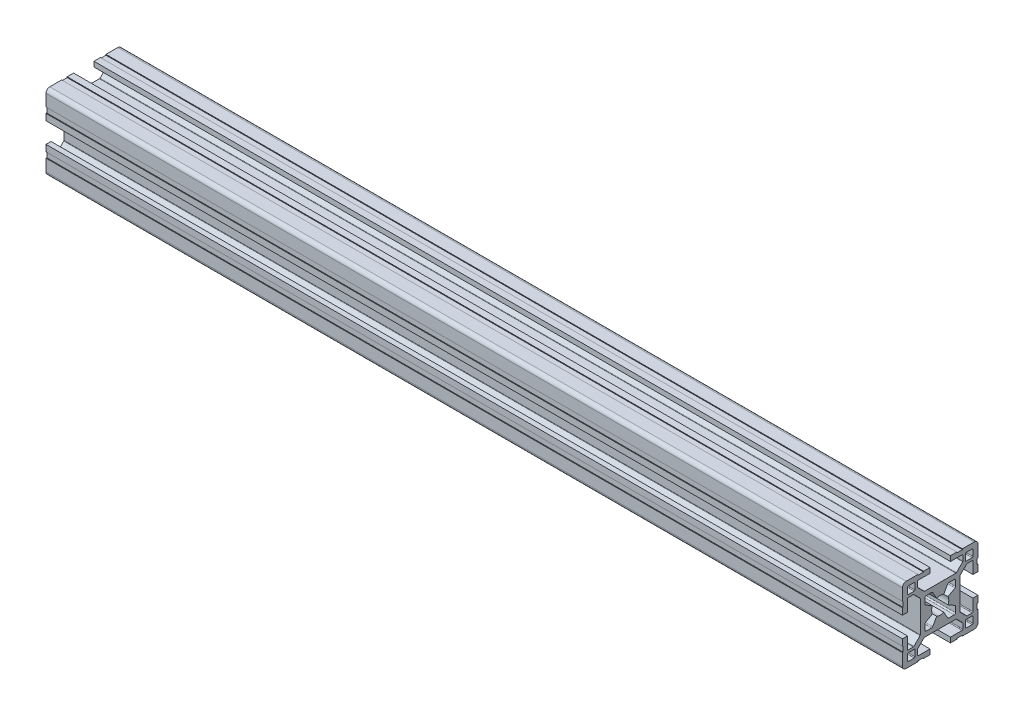
from build123d import *

# Parameters (mm, degrees)
QUADRADO_PF30_11_PERFIL_3030_CENTRO_M8_DEPTH = 340


with BuildPart() as part:
    # Sketch1 → Quadrado PF30-11 - PERFIL 3030 CENTRO M8(1) (new body)
    with BuildSketch(Plane.YZ):
        with BuildLine():
            Line((14.999995923, 6.599996803), (14.699995923, 6.599996803))
            Line((14.699995923, 6.599996803), (14.699995923, 8.799996803))
            Line((14.699995923, 8.799996803), (14.999995923, 8.799996803))
            Line((14.999995923, 8.799996803), (14.999995923, 13.499995825))
            ThreePointArc((14.999995923, 13.499995825), (14.560656066, 14.560656066), (13.499995825, 14.999995923))
            Line((13.499995825, 14.999995923), (8.799996818, 14.999995923))
            Line((8.799996818, 14.999995923), (8.799996818, 14.699995923))
            Line((8.799996818, 14.699995923), (6.599996818, 14.699995923))
            Line((6.599996818, 14.699995923), (6.599996818, 14.999995923))
            Line((6.599996818, 14.999995923), (4.0499987, 14.999995923))
            Line((4.0499987, 14.999995923), (4.0499987, 12.999995366))
            Line((4.0499987, 12.999995366), (8.699997649, 12.999995366))
            ThreePointArc((8.699997649, 12.999995366), (8.912129683, 12.9121274), (8.999997649, 12.699995366))
            Line((8.999997649, 12.699995366), (8.999997649, 10.679894006))
            ThreePointArc((8.999997649, 10.679894006), (8.977161511, 10.565088981), (8.912129691, 10.467761979))
            Line((8.912129691, 10.467761979), (6.432230191, 7.987862303))
            ThreePointArc((6.432230191, 7.987862303), (6.334903184, 7.922830472), (6.220098149, 7.89999433))
            Line((6.220098149, 7.89999433), (-6.220098149, 7.89999433))
            ThreePointArc((-6.220098149, 7.89999433), (-6.334903184, 7.922830472), (-6.432230191, 7.987862303))
            Line((-6.432230191, 7.987862303), (-8.912129691, 10.467761979))
            ThreePointArc((-8.912129691, 10.467761979), (-8.977161511, 10.565088981), (-8.999997649, 10.679894006))
            Line((-8.999997649, 10.679894006), (-8.999997649, 12.699995366))
            ThreePointArc((-8.999997649, 12.699995366), (-8.912129683, 12.9121274), (-8.699997649, 12.999995366))
            Line((-8.699997649, 12.999995366), (-4.0499987, 12.999995366))
            Line((-4.0499987, 12.999995366), (-4.0499987, 14.999995923))
            Line((-4.0499987, 14.999995923), (-6.599996818, 14.999995923))
            Line((-6.599996818, 14.999995923), (-6.599996818, 14.699995923))
            Line((-6.599996818, 14.699995923), (-8.799996818, 14.699995923))
            Line((-8.799996818, 14.699995923), (-8.799996818, 14.999995923))
            Line((-8.799996818, 14.999995923), (-13.499995825, 14.999995923))
            ThreePointArc((-13.499995825, 14.999995923), (-14.560656066, 14.560656066), (-14.999995923, 13.499995825))
            Line((-14.999995923, 13.499995825), (-14.999995923, 8.799996803))
            Line((-14.999995923, 8.799996803), (-14.699995923, 8.799996803))
            Line((-14.699995923, 8.799996803), (-14.699995923, 6.599996803))
            Line((-14.699995923, 6.599996803), (-14.999995923, 6.599996803))
            Line((-14.999995923, 6.599996803), (-14.999995923, 4.0499987))
            Line((-14.999995923, 4.0499987), (-12.999995366, 4.0499987))
            Line((-12.999995366, 4.0499987), (-12.999995366, 8.699997649))
            ThreePointArc((-12.999995366, 8.699997649), (-12.9121274, 8.912129683), (-12.699995366, 8.999997649))
            Line((-12.699995366, 8.999997649), (-10.679894006, 8.999997649))
            ThreePointArc((-10.679894006, 8.999997649), (-10.565088981, 8.977161511), (-10.467761979, 8.912129691))
            Line((-10.467761979, 8.912129691), (-7.987862303, 6.432230191))
            ThreePointArc((-7.987862303, 6.432230191), (-7.922830472, 6.334903184), (-7.89999433, 6.220098149))
            Line((-7.89999433, 6.220098149), (-7.89999433, -6.220098149))
            ThreePointArc((-7.89999433, -6.220098149), (-7.922830472, -6.334903184), (-7.987862303, -6.432230191))
            Line((-7.987862303, -6.432230191), (-10.467761979, -8.912129691))
            ThreePointArc((-10.467761979, -8.912129691), (-10.565088981, -8.977161511), (-10.679894006, -8.999997649))
            Line((-10.679894006, -8.999997649), (-12.699995366, -8.999997649))
            ThreePointArc((-12.699995366, -8.999997649), (-12.9121274, -8.912129683), (-12.999995366, -8.699997649))
            Line((-12.999995366, -8.699997649), (-12.999995366, -4.0499987))
            Line((-12.999995366, -4.0499987), (-14.999995923, -4.0499987))
            Line((-14.999995923, -4.0499987), (-14.999995923, -6.599996803))
            Line((-14.999995923, -6.599996803), (-14.699995923, -6.599996803))
            Line((-14.699995923, -6.599996803), (-14.699995923, -8.799996803))
            Line((-14.699995923, -8.799996803), (-14.999995923, -8.799996803))
            Line((-14.999995923, -8.799996803), (-14.999995923, -13.499995825))
            ThreePointArc((-14.999995923, -13.499995825), (-14.560656066, -14.560656066), (-13.499995825, -14.999995923))
            Line((-13.499995825, -14.999995923), (-8.799996818, -14.999995923))
            Line((-8.799996818, -14.999995923), (-8.799996818, -14.699995923))
            Line((-8.799996818, -14.699995923), (-6.599996818, -14.699995923))
            Line((-6.599996818, -14.699995923), (-6.599996818, -14.999995923))
            Line((-6.599996818, -14.999995923), (-4.0499987, -14.999995923))
            Line((-4.0499987, -14.999995923), (-4.0499987, -12.999995366))
            Line((-4.0499987, -12.999995366), (-8.699997649, -12.999995366))
            ThreePointArc((-8.699997649, -12.999995366), (-8.912129683, -12.9121274), (-8.999997649, -12.699995366))
            Line((-8.999997649, -12.699995366), (-8.999997649, -10.679894006))
            ThreePointArc((-8.999997649, -10.679894006), (-8.977161511, -10.565088981), (-8.912129691, -10.467761979))
            Line((-8.912129691, -10.467761979), (-6.432230191, -7.987862303))
            ThreePointArc((-6.432230191, -7.987862303), (-6.334903184, -7.922830472), (-6.220098149, -7.89999433))
            Line((-6.220098149, -7.89999433), (6.220098149, -7.89999433))
            ThreePointArc((6.220098149, -7.89999433), (6.334903184, -7.922830472), (6.432230191, -7.987862303))
            Line((6.432230191, -7.987862303), (8.912129691, -10.467761979))
            ThreePointArc((8.912129691, -10.467761979), (8.977161511, -10.565088981), (8.999997649, -10.679894006))
            Line((8.999997649, -10.679894006), (8.999997649, -12.699995366))
            ThreePointArc((8.999997649, -12.699995366), (8.912129683, -12.9121274), (8.699997649, -12.999995366))
            Line((8.699997649, -12.999995366), (4.0499987, -12.999995366))
            Line((4.0499987, -12.999995366), (4.0499987, -14.999995923))
            Line((4.0499987, -14.999995923), (6.599996818, -14.999995923))
            Line((6.599996818, -14.999995923), (6.599996818, -14.699995923))
            Line((6.599996818, -14.699995923), (8.799996818, -14.699995923))
            Line((8.799996818, -14.699995923), (8.799996818, -14.999995923))
            Line((8.799996818, -14.999995923), (13.499995825, -14.999995923))
            ThreePointArc((13.499995825, -14.999995923), (14.560656066, -14.560656066), (14.999995923, -13.499995825))
            Line((14.999995923, -13.499995825), (14.999995923, -8.799996803))
            Line((14.999995923, -8.799996803), (14.699995923, -8.799996803))
            Line((14.699995923, -8.799996803), (14.699995923, -6.599996803))
            Line((14.699995923, -6.599996803), (14.999995923, -6.599996803))
            Line((14.999995923, -6.599996803), (14.999995923, -4.0499987))
            Line((14.999995923, -4.0499987), (12.999995366, -4.0499987))
            Line((12.999995366, -4.0499987), (12.999995366, -8.699997649))
            ThreePointArc((12.999995366, -8.699997649), (12.9121274, -8.912129683), (12.699995366, -8.999997649))
            Line((12.699995366, -8.999997649), (10.679894006, -8.999997649))
            ThreePointArc((10.679894006, -8.999997649), (10.565088981, -8.977161511), (10.467761979, -8.912129691))
            Line((10.467761979, -8.912129691), (7.987862303, -6.432230191))
            ThreePointArc((7.987862303, -6.432230191), (7.922830472, -6.334903184), (7.89999433, -6.220098149))
            Line((7.89999433, -6.220098149), (7.89999433, 6.220098149))
            ThreePointArc((7.89999433, 6.220098149), (7.922830472, 6.334903184), (7.987862303, 6.432230191))
            Line((7.987862303, 6.432230191), (10.467761979, 8.912129691))
            ThreePointArc((10.467761979, 8.912129691), (10.565088981, 8.977161511), (10.679894006, 8.999997649))
            Line((10.679894006, 8.999997649), (12.699995366, 8.999997649))
            ThreePointArc((12.699995366, 8.999997649), (12.9121274, 8.912129683), (12.999995366, 8.699997649))
            Line((12.999995366, 8.699997649), (12.999995366, 4.0499987))
            Line((12.999995366, 4.0499987), (14.999995923, 4.0499987))
            Line((14.999995923, 4.0499987), (14.999995923, 6.599996803))
        make_face()
        with BuildLine():
            Line((-6.1, -3.425408784), (-6.1, -5.6))
            ThreePointArc((-6.1, -5.6), (-5.953553391, -5.953553391), (-5.6, -6.1))
            Line((-5.6, -6.1), (-3.425408784, -6.1))
            ThreePointArc((-3.425408784, -6.1), (-3.175408784, -6.033012702), (-2.992396082, -5.85))
            Line((-2.992396082, -5.85), (-1.402974441, -3.097040962))
            ThreePointArc((-1.402974441, -3.097040962), (0, -3.4), (1.402974441, -3.097040962))
            Line((1.402974441, -3.097040962), (2.992396082, -5.85))
            ThreePointArc((2.992396082, -5.85), (3.175408784, -6.033012702), (3.425408784, -6.1))
            Line((3.425408784, -6.1), (5.6, -6.1))
            ThreePointArc((5.6, -6.1), (5.953553391, -5.953553391), (6.1, -5.6))
            Line((6.1, -5.6), (6.1, -3.425408784))
            ThreePointArc((6.1, -3.425408784), (6.033012702, -3.175408784), (5.85, -2.992396082))
            Line((5.85, -2.992396082), (3.097040962, -1.402974441))
            ThreePointArc((3.097040962, -1.402974441), (3.4, 0), (3.097040962, 1.402974441))
            Line((3.097040962, 1.402974441), (5.85, 2.992396082))
            ThreePointArc((5.85, 2.992396082), (6.033012702, 3.175408784), (6.1, 3.425408784))
            Line((6.1, 3.425408784), (6.1, 5.6))
            ThreePointArc((6.1, 5.6), (5.953553391, 5.953553391), (5.6, 6.1))
            Line((5.6, 6.1), (3.425408784, 6.1))
            ThreePointArc((3.425408784, 6.1), (3.175408784, 6.033012702), (2.992396082, 5.85))
            Line((2.992396082, 5.85), (1.402974441, 3.097040962))
            ThreePointArc((1.402974441, 3.097040962), (0, 3.4), (-1.402974441, 3.097040962))
            Line((-1.402974441, 3.097040962), (-2.992396082, 5.85))
            ThreePointArc((-2.992396082, 5.85), (-3.175408784, 6.033012702), (-3.425408784, 6.1))
            Line((-3.425408784, 6.1), (-5.6, 6.1))
            ThreePointArc((-5.6, 6.1), (-5.953553391, 5.953553391), (-6.1, 5.6))
            Line((-6.1, 5.6), (-6.1, 3.425408784))
            ThreePointArc((-6.1, 3.425408784), (-6.033012702, 3.175408784), (-5.85, 2.992396082))
            Line((-5.85, 2.992396082), (-3.097040962, 1.402974441))
            ThreePointArc((-3.097040962, 1.402974441), (-3.4, 0), (-3.097040962, -1.402974441))
            Line((-3.097040962, -1.402974441), (-5.85, -2.992396082))
            ThreePointArc((-5.85, -2.992396082), (-6.033012702, -3.175408784), (-6.1, -3.425408784))
        make_face(mode=Mode.SUBTRACT)
        with BuildLine():
            Line((9.999995366, 12.699997649), (9.999995366, 10.299997649))
            ThreePointArc((9.999995366, 10.299997649), (10.087863331, 10.087865615), (10.299995366, 9.999997649))
            Line((10.299995366, 9.999997649), (12.699995366, 9.999997649))
            ThreePointArc((12.699995366, 9.999997649), (12.9121274, 10.087865615), (12.999995366, 10.299997649))
            Line((12.999995366, 10.299997649), (12.999995366, 12.699997649))
            ThreePointArc((12.999995366, 12.699997649), (12.9121274, 12.912129683), (12.699995366, 12.999997649))
            Line((12.699995366, 12.999997649), (10.299995366, 12.999997649))
            ThreePointArc((10.299995366, 12.999997649), (10.087863331, 12.912129683), (9.999995366, 12.699997649))
        make_face(mode=Mode.SUBTRACT)
        with BuildLine():
            Line((12.999995366, -12.699997649), (12.999995366, -10.299997649))
            ThreePointArc((12.999995366, -10.299997649), (12.9121274, -10.087865615), (12.699995366, -9.999997649))
            Line((12.699995366, -9.999997649), (10.299995366, -9.999997649))
            ThreePointArc((10.299995366, -9.999997649), (10.087863331, -10.087865615), (9.999995366, -10.299997649))
            Line((9.999995366, -10.299997649), (9.999995366, -12.699997649))
            ThreePointArc((9.999995366, -12.699997649), (10.087863331, -12.912129683), (10.299995366, -12.999997649))
            Line((10.299995366, -12.999997649), (12.699995366, -12.999997649))
            ThreePointArc((12.699995366, -12.999997649), (12.9121274, -12.912129683), (12.999995366, -12.699997649))
        make_face(mode=Mode.SUBTRACT)
        with BuildLine():
            Line((-10.299995366, -9.999997649), (-12.699995366, -9.999997649))
            ThreePointArc((-12.699995366, -9.999997649), (-12.9121274, -10.087865615), (-12.999995366, -10.299997649))
            Line((-12.999995366, -10.299997649), (-12.999995366, -12.699997649))
            ThreePointArc((-12.999995366, -12.699997649), (-12.9121274, -12.912129683), (-12.699995366, -12.999997649))
            Line((-12.699995366, -12.999997649), (-10.299995366, -12.999997649))
            ThreePointArc((-10.299995366, -12.999997649), (-10.087863331, -12.912129683), (-9.999995366, -12.699997649))
            Line((-9.999995366, -12.699997649), (-9.999995366, -10.299997649))
            ThreePointArc((-9.999995366, -10.299997649), (-10.087863331, -10.087865615), (-10.299995366, -9.999997649))
        make_face(mode=Mode.SUBTRACT)
        with BuildLine():
            Line((-12.999995366, 12.699997649), (-12.999995366, 10.299997649))
            ThreePointArc((-12.999995366, 10.299997649), (-12.9121274, 10.087865615), (-12.699995366, 9.999997649))
            Line((-12.699995366, 9.999997649), (-10.299995366, 9.999997649))
            ThreePointArc((-10.299995366, 9.999997649), (-10.087863331, 10.087865615), (-9.999995366, 10.299997649))
            Line((-9.999995366, 10.299997649), (-9.999995366, 12.699997649))
            ThreePointArc((-9.999995366, 12.699997649), (-10.087863331, 12.912129683), (-10.299995366, 12.999997649))
            Line((-10.299995366, 12.999997649), (-12.699995366, 12.999997649))
            ThreePointArc((-12.699995366, 12.999997649), (-12.9121274, 12.912129683), (-12.999995366, 12.699997649))
        make_face(mode=Mode.SUBTRACT)
    extrude(amount=QUADRADO_PF30_11_PERFIL_3030_CENTRO_M8_DEPTH)


solid = part.part
